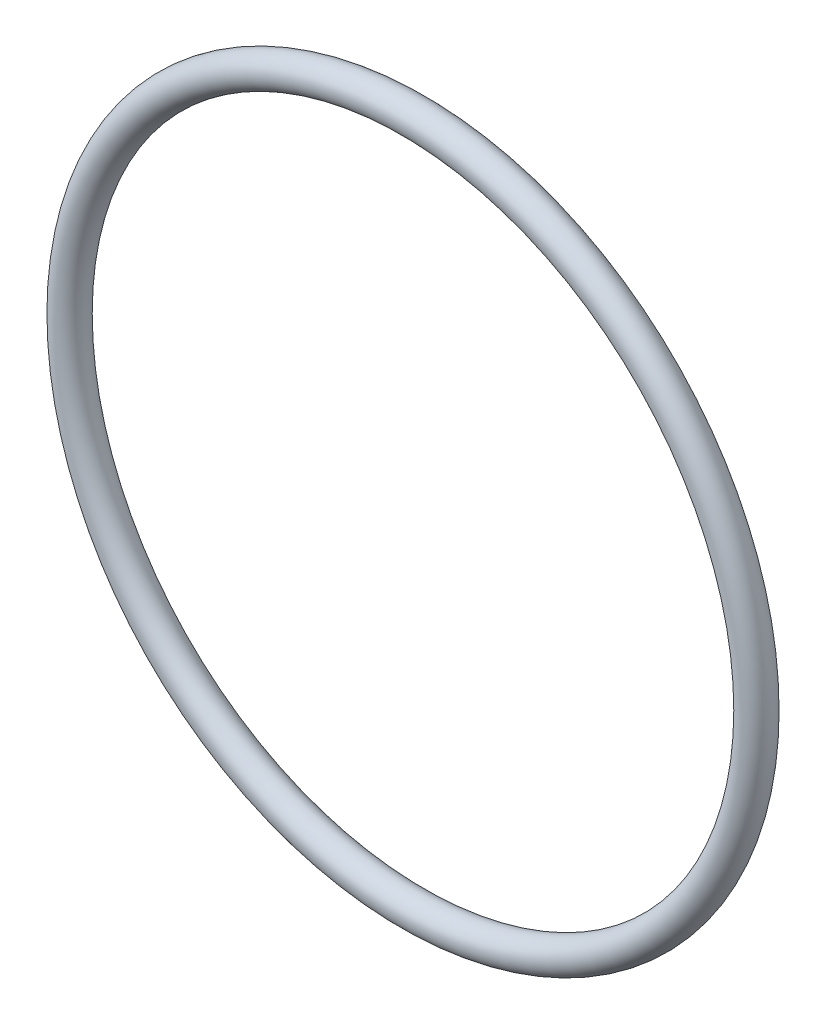
from build123d import *

# Parameters (mm, degrees)
SKETCH1_R = 0.7


with BuildPart() as part:
    # Sketch1 → Revolve1 (revolve)
    with BuildSketch(Plane(origin=(0, 0, 0), x_dir=(1, 0, 0), z_dir=(0, 1, 0))):
        with Locations((15, 0)):
            Circle(SKETCH1_R)
    revolve(axis=Axis((0, 0, 0), (0, 0, -1)))


solid = part.part
